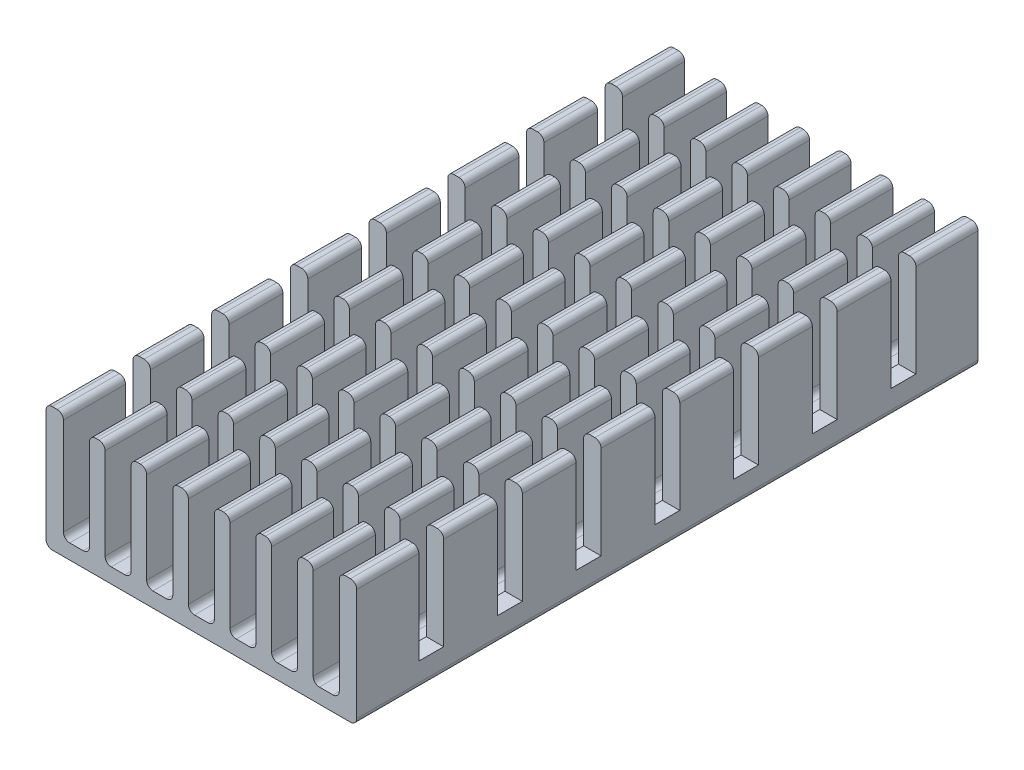
from build123d import *

# Parameters (mm, degrees)
BOSS_EXTRUDE1_DEPTH = 50
FILLET1_R           = 0.5
SKETCH2_W           = 2
SKETCH2_H           = 7.990678459
CUT_EXTRUDE1_DEPTH  = 26


with BuildPart() as part:
    # Sketch1 → Boss-Extrude1 (new body)
    with BuildSketch(Plane.XY):
        Polygon((0, 0), (0, 10), (1.4, 10), (1.4, 1.2), (3.5, 1.2), (3.5, 9.539350181), (4.75, 9.539350181), (4.75, 1.2), (6.85, 1.2), (6.85, 9.539350181), (8.1, 9.539350181), (8.1, 1.2), (10.2, 1.2), (10.2, 9.539350181), (11.45, 9.539350181), (11.45, 1.2), (13.55, 1.2), (13.55, 9.539350181), (14.8, 9.539350181), (14.8, 1.2), (16.9, 1.2), (16.9, 9.539350181), (18.15, 9.539350181), (18.15, 1.2), (20.25, 1.2), (20.25, 9.539350181), (21.5, 9.539350181), (21.5, 1.2), (23.6, 1.2), (23.6, 10), (25, 10), (25, 0), align=None)
    extrude(amount=BOSS_EXTRUDE1_DEPTH)

    # Fillet1
    fillet1_edges = [part.edges().sort_by_distance(p)[0] for p in [
        (0, 0, 25),
        (0, 10, 25),
        (1.4, 10, 25),
        (1.4, 1.2, 25),
        (3.5, 1.2, 25),
        (3.5, 9.539350181, 25),
        (4.75, 9.539350181, 25),
        (4.75, 1.2, 25),
        (6.85, 1.2, 25),
        (6.85, 9.539350181, 25),
        (8.1, 9.539350181, 25),
        (8.1, 1.2, 25),
        (10.2, 1.2, 25),
        (10.2, 9.539350181, 25),
        (11.45, 9.539350181, 25),
        (11.45, 1.2, 25),
        (13.55, 1.2, 25),
        (13.55, 9.539350181, 25),
        (14.8, 9.539350181, 25),
        (14.8, 1.2, 25),
        (16.9, 1.2, 25),
        (16.9, 9.539350181, 25),
        (18.15, 9.539350181, 25),
        (18.15, 1.2, 25),
        (20.25, 1.2, 25),
        (20.25, 9.539350181, 25),
        (21.5, 9.539350181, 25),
        (21.5, 1.2, 25),
        (23.6, 1.2, 25),
        (23.6, 10, 25),
        (25, 10, 25),
        (25, 0, 25),
    ]]
    fillet(fillet1_edges, radius=FILLET1_R)

    # Sketch2 → Cut-Extrude1 (cut, through all)
    with BuildSketch(Plane(origin=(25, 0, 0), x_dir=(0, 0, -1), z_dir=(1, 0, 0))):
        with Locations((-6, 6.004660771)):
            Rectangle(SKETCH2_W, SKETCH2_H)
        with Locations((-12.333333333, 6.004660771)):
            Rectangle(SKETCH2_W, SKETCH2_H)
        with Locations((-18.666666667, 6.004660771)):
            Rectangle(SKETCH2_W, SKETCH2_H)
        with Locations((-25, 6.004660771)):
            Rectangle(SKETCH2_W, SKETCH2_H)
        with Locations((-31.333333333, 6.004660771)):
            Rectangle(SKETCH2_W, SKETCH2_H)
        with Locations((-37.666666667, 6.004660771)):
            Rectangle(SKETCH2_W, SKETCH2_H)
        with Locations((-44, 6.004660771)):
            Rectangle(SKETCH2_W, SKETCH2_H)
    extrude(amount=-CUT_EXTRUDE1_DEPTH, mode=Mode.SUBTRACT)


solid = part.part
